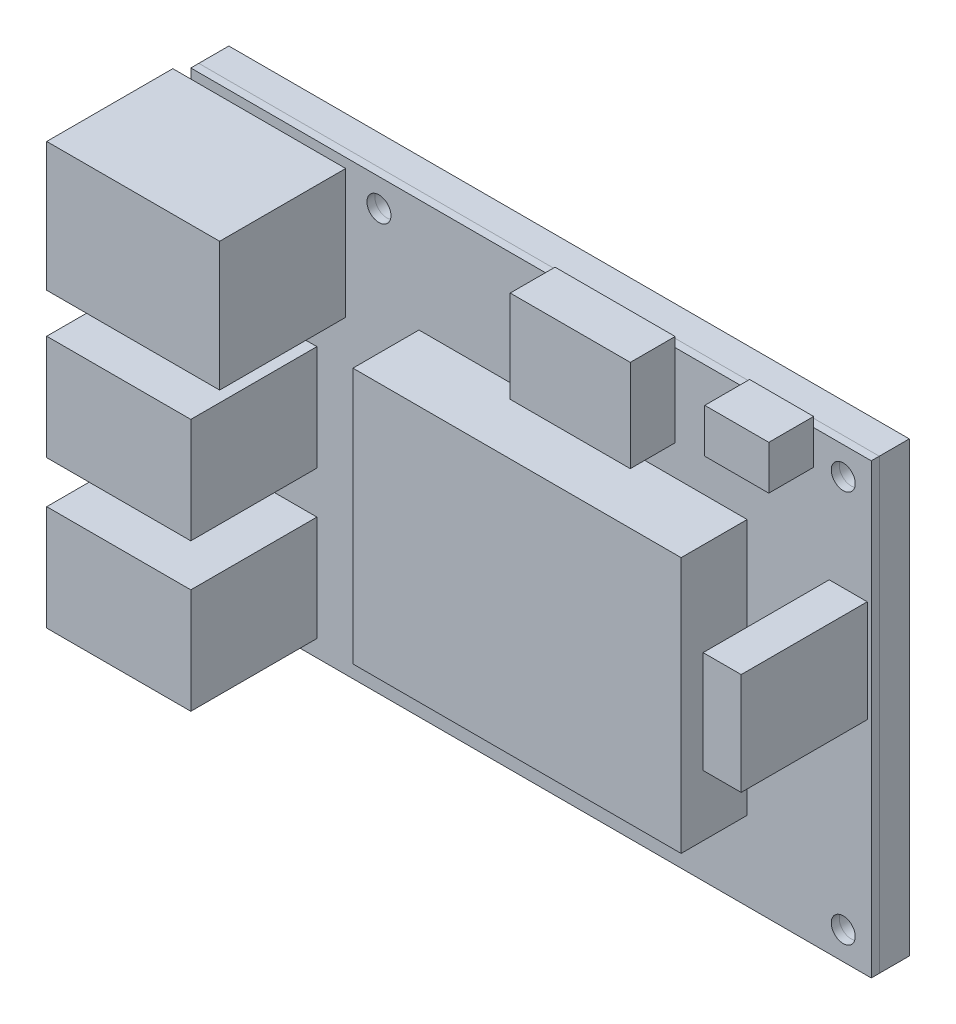
from build123d import *

# Parameters (mm, degrees)
SKETCH1_W                         = 85
SKETCH1_H                         = 55.95
SKETCH1_R                         = 1.5
BOSS_EXTRUDE1_DEPTH               = 1
SKETCH1_2_W                       = 85
SKETCH1_2_H                       = 55.95
SKETCH1_2_R                       = 1.5
BOSS_EXTRUDE2_LOWER_KEEPOUT_DEPTH = 3.75
SKETCH3_W                         = 41
SKETCH3_H                         = 32
BOSS_EXTRUDE3_DEPTH               = 8.25
SKETCH4_W                         = 18
SKETCH4_H                         = 13.14
SKETCH4_W_2                       = 4.755
SKETCH4_H_2                       = 12.75
SKETCH4_W_3                       = 21.6
SKETCH4_H_3                       = 16.1
BOSS_EXTRUDE4_DEPTH               = 15.75
SKETCH5_W                         = 15
SKETCH5_H                         = 11.5
SKETCH5_W_2                       = 8
SKETCH5_H_2                       = 5.5
BOSS_EXTRUDE5_DEPTH               = 5.6
SKETCH6_W                         = 11.61
SKETCH6_H                         = 15.75
BOSS_EXTRUDE6_DEPTH               = 4
SKETCH7_W                         = 5
SKETCH7_H                         = 10.304554558
CUT_EXTRUDE1_DEPTH                = 12
MIRROR2_COPY_1_SKETCH_W           = 5
MIRROR2_COPY_1_SKETCH_H           = 10.304554558
MIRROR2_COPY_1_DEPTH              = 12
MIRROR2_COPY_2_SKETCH_W           = 5
MIRROR2_COPY_2_SKETCH_H           = 10.304554558
MIRROR2_COPY_2_DEPTH              = 12


with BuildPart() as part:
    # Sketch1 → Boss-Extrude1 (new body)
    with BuildSketch(Plane.XY):
        Rectangle(SKETCH1_W, SKETCH1_H)
        with Locations((-19.000000078, 24.5)):
            Circle(SKETCH1_R, mode=Mode.SUBTRACT)
        with Locations((-19.000000078, -24.5)):
            Circle(SKETCH1_R, mode=Mode.SUBTRACT)
        with Locations((39, 24.5)):
            Circle(SKETCH1_R, mode=Mode.SUBTRACT)
        with Locations((39, -24.5)):
            Circle(SKETCH1_R, mode=Mode.SUBTRACT)
    extrude(amount=BOSS_EXTRUDE1_DEPTH)

    # Sketch3 → Boss-Extrude3 (add)
    with BuildSketch(Plane.XY.offset(1)):
        with Locations((6.5, -2.125)):
            Rectangle(SKETCH3_W, SKETCH3_H)
    extrude(amount=BOSS_EXTRUDE3_DEPTH)

    # Sketch4 → Boss-Extrude4 (add)
    with BuildSketch(Plane.XY.offset(1)):
        with Locations((-35.74947609, -0.865)):
            Rectangle(SKETCH4_W, SKETCH4_H)
        with Locations((-35.74947609, -19.305)):
            Rectangle(SKETCH4_W, SKETCH4_H)
        with Locations((39.6225, 6.1)):
            Rectangle(SKETCH4_W_2, SKETCH4_H_2)
        with Locations((-33.94947609, 18.725)):
            Rectangle(SKETCH4_W_3, SKETCH4_H_3)
    extrude(amount=BOSS_EXTRUDE4_DEPTH)

    # Sketch5 → Boss-Extrude5 (add)
    with BuildSketch(Plane.XY.offset(1)):
        with Locations((10.5, 23.425)):
            Rectangle(SKETCH5_W, SKETCH5_H)
        with Locations((31.3, 26.425)):
            Rectangle(SKETCH5_W_2, SKETCH5_H_2)
    extrude(amount=BOSS_EXTRUDE5_DEPTH)

    # Sketch7 → Cut-Extrude1 (cut)
    with BuildSketch(Plane.ZY.offset(44.74947609)):
        with Locations((5.2, -19.307277279)):
            Rectangle(SKETCH7_W, SKETCH7_H)
    cut_extrude1 = extrude(amount=-CUT_EXTRUDE1_DEPTH, mode=Mode.SUBTRACT)

    # Mirror1: Cut-Extrude1 across plane
    add(cut_extrude1.mirror(Plane.XY.offset(8.875)), mode=Mode.SUBTRACT)

    # Mirror2 copy 1 sketch → Mirror2 copy 1 (cut)
    with BuildSketch(Plane(origin=(-44.74947609, -20.17, 17.75), x_dir=(0, 0, -1), z_dir=(-1, 0, 0))):
        with Locations((5.2, -19.307277279)):
            Rectangle(MIRROR2_COPY_1_SKETCH_W, MIRROR2_COPY_1_SKETCH_H)
    extrude(amount=-MIRROR2_COPY_1_DEPTH, mode=Mode.SUBTRACT)

    # Mirror2 copy 2 sketch → Mirror2 copy 2 (cut)
    with BuildSketch(Plane(origin=(-44.74947609, -20.17, 0), x_dir=(0, 0, 1), z_dir=(-1, 0, 0))):
        with Locations((5.2, 19.307277279)):
            Rectangle(MIRROR2_COPY_2_SKETCH_W, MIRROR2_COPY_2_SKETCH_H)
    extrude(amount=-MIRROR2_COPY_2_DEPTH, mode=Mode.SUBTRACT)


with BuildPart() as body_2:
    # Sketch1_2 → Boss-Extrude2-lower-keepout (new body)
    with BuildSketch(Plane.XY):
        Rectangle(SKETCH1_2_W, SKETCH1_2_H)
        with Locations((-19.000000078, 24.5)):
            Circle(SKETCH1_2_R, mode=Mode.SUBTRACT)
        with Locations((-19.000000078, -24.5)):
            Circle(SKETCH1_2_R, mode=Mode.SUBTRACT)
        with Locations((39, 24.5)):
            Circle(SKETCH1_2_R, mode=Mode.SUBTRACT)
        with Locations((39, -24.5)):
            Circle(SKETCH1_2_R, mode=Mode.SUBTRACT)
    extrude(amount=-BOSS_EXTRUDE2_LOWER_KEEPOUT_DEPTH)


with BuildPart() as body_3:
    # Sketch6 → Boss-Extrude6 (new body)
    with BuildSketch(Plane.XY):
        with Locations((-6.401910681, -20.6)):
            Rectangle(SKETCH6_W, SKETCH6_H)
    extrude(amount=-BOSS_EXTRUDE6_DEPTH)


solid = Compound([part.part, body_2.part, body_3.part])
